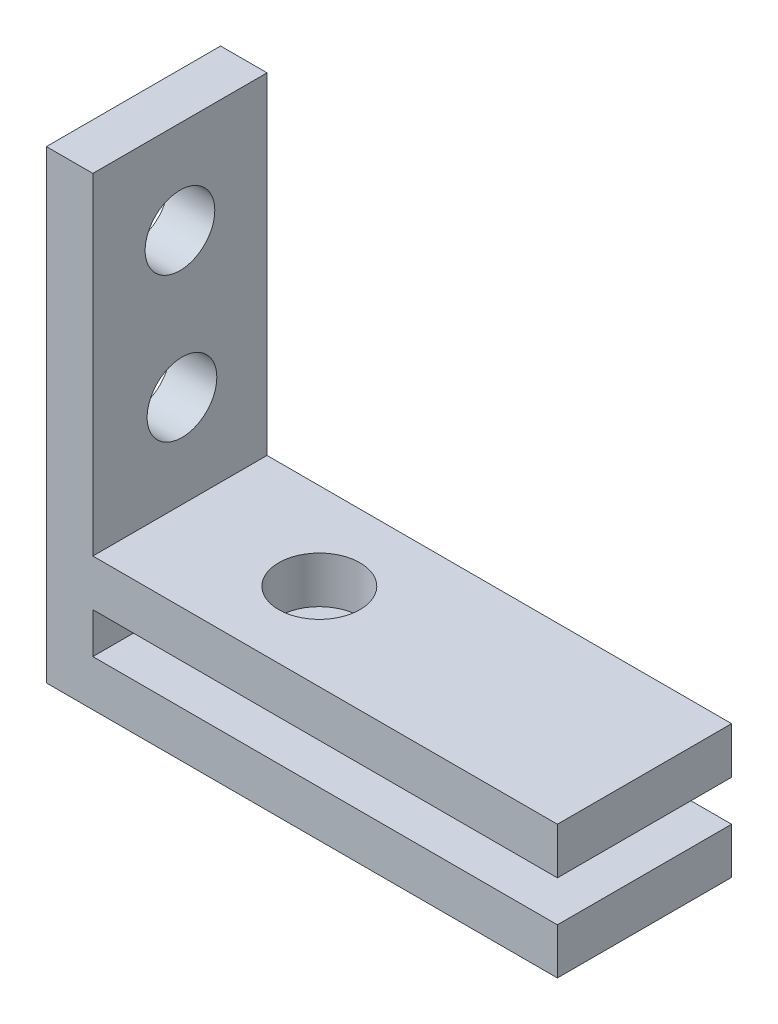
from build123d import *

# Parameters (mm, degrees)
SKETCH1_W           = 7.5
SKETCH1_H           = 20
BOSS_EXTRUDE2_DEPTH = 2
SKETCH2_W           = 7.5
SKETCH2_H           = 1.98347932
BOSS_EXTRUDE3_DEPTH = 20
SKETCH3_W           = 7.5
SKETCH3_H           = 2
BOSS_EXTRUDE4_DEPTH = 20
SKETCH5_R           = 1.5
CUT_EXTRUDE1_DEPTH  = 20
SKETCH6_R           = 1.75
CUT_EXTRUDE2_DEPTH  = 10


with BuildPart() as part:
    # Sketch1 → Boss-Extrude2 (new body)
    with BuildSketch(Plane(origin=(0, 0, 0), x_dir=(0, 0, -1), z_dir=(1, 0, 0))):
        with Locations((3.009581882, -0.975609756)):
            Rectangle(SKETCH1_W, SKETCH1_H)
    extrude(amount=BOSS_EXTRUDE2_DEPTH)

    # Sketch2 → Boss-Extrude3 (add)
    with BuildSketch(Plane(origin=(2, 0, 0), x_dir=(0, 0, -1), z_dir=(1, 0, 0))):
        with Locations((3.009581882, -9.983870096)):
            Rectangle(SKETCH2_W, SKETCH2_H)
    extrude(amount=BOSS_EXTRUDE3_DEPTH)

    # Sketch3 → Boss-Extrude4 (add)
    with BuildSketch(Plane(origin=(2, 0, 0), x_dir=(0, 0, -1), z_dir=(1, 0, 0))):
        with Locations((3.009581882, -6.242130436)):
            Rectangle(SKETCH3_W, SKETCH3_H)
    extrude(amount=BOSS_EXTRUDE4_DEPTH)

    # Sketch5 → Cut-Extrude1 (cut)
    with BuildSketch(Plane(origin=(2, 0, 0), x_dir=(0, 0, -1), z_dir=(1, 0, 0))):
        with Locations((3.009581882, 5.024390244)):
            Circle(SKETCH5_R)
        with Locations((3.096458319, -1.242130436)):
            Circle(SKETCH5_R)
    extrude(amount=-CUT_EXTRUDE1_DEPTH, mode=Mode.SUBTRACT)

    # Sketch6 → Cut-Extrude2 (cut)
    with BuildSketch(Plane(origin=(0, -5.242130436, 0), x_dir=(1, 0, 0), z_dir=(0, 1, 0))):
        with Locations((8, 3.009581882)):
            Circle(SKETCH6_R)
    extrude(amount=-CUT_EXTRUDE2_DEPTH, mode=Mode.SUBTRACT)


solid = part.part
